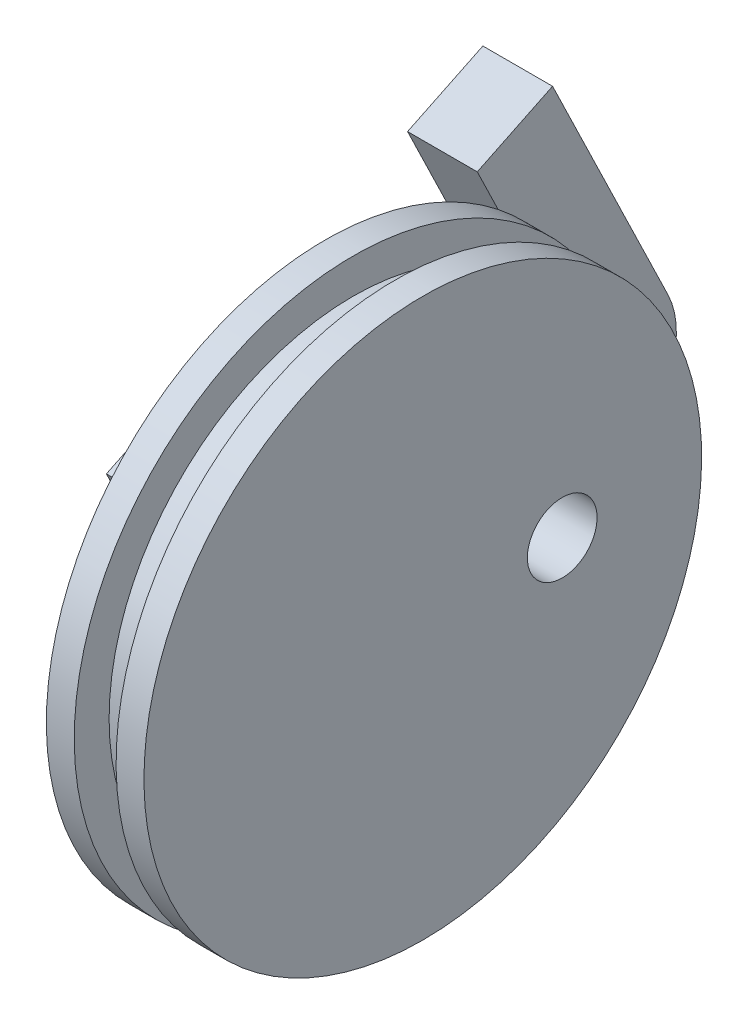
from build123d import *

# Parameters (mm, degrees)
BOSS_EXTRUDE1_DEPTH = 5
SKETCH4_R           = 2.5
CUT_EXTRUDE1_DEPTH  = 8


with BuildPart() as part:
    # Sketch1 → Revolve1 (revolve)
    with BuildSketch(Plane.XY):
        Polygon((-3.5, 20), (-3.5, 0), (3.5, 0), (3.5, 20), (1.5, 20), (1.5, 17.5), (-1.5, 17.5), (-1.5, 20), align=None)
    revolve(axis=Axis((-3.5, 0, 0), (1, 0, 0)))

    # Sketch3 → Boss-Extrude1 (add)
    with BuildSketch(Plane.ZY.offset(3.5)):
        with BuildLine():
            Line((-10.907816743, 18.773009049), (-19.189724736, 1.673009049))
            Line((-19.189724736, 1.673009049), (-2.989724736, -6.173009049))
            Line((-2.989724736, -6.173009049), (5.292183257, 10.926990951))
            Line((5.292183257, 10.926990951), (10.692183257, 8.311651585))
            Line((10.692183257, 8.311651585), (2.410275264, -8.788348415))
            ThreePointArc((2.410275264, -8.788348415), (-1.020672318, -11.840709868), (-5.605064102, -11.573009049))
            Line((-5.605064102, -11.573009049), (-21.805064102, -3.726990951))
            ThreePointArc((-21.805064102, -3.726990951), (-24.857425555, -0.296043368), (-24.589724736, 4.288348415))
            Line((-24.589724736, 4.288348415), (-16.307816743, 21.388348415))
            Line((-16.307816743, 21.388348415), (-10.907816743, 18.773009049))
        make_face()
    extrude(amount=BOSS_EXTRUDE1_DEPTH)

    # Sketch4 → Cut-Extrude1 (cut, through all)
    with BuildSketch(Plane.ZY.offset(3.5)):
        with Locations((-10, 0)):
            Circle(SKETCH4_R)
    extrude(amount=-CUT_EXTRUDE1_DEPTH, mode=Mode.SUBTRACT)


solid = part.part
